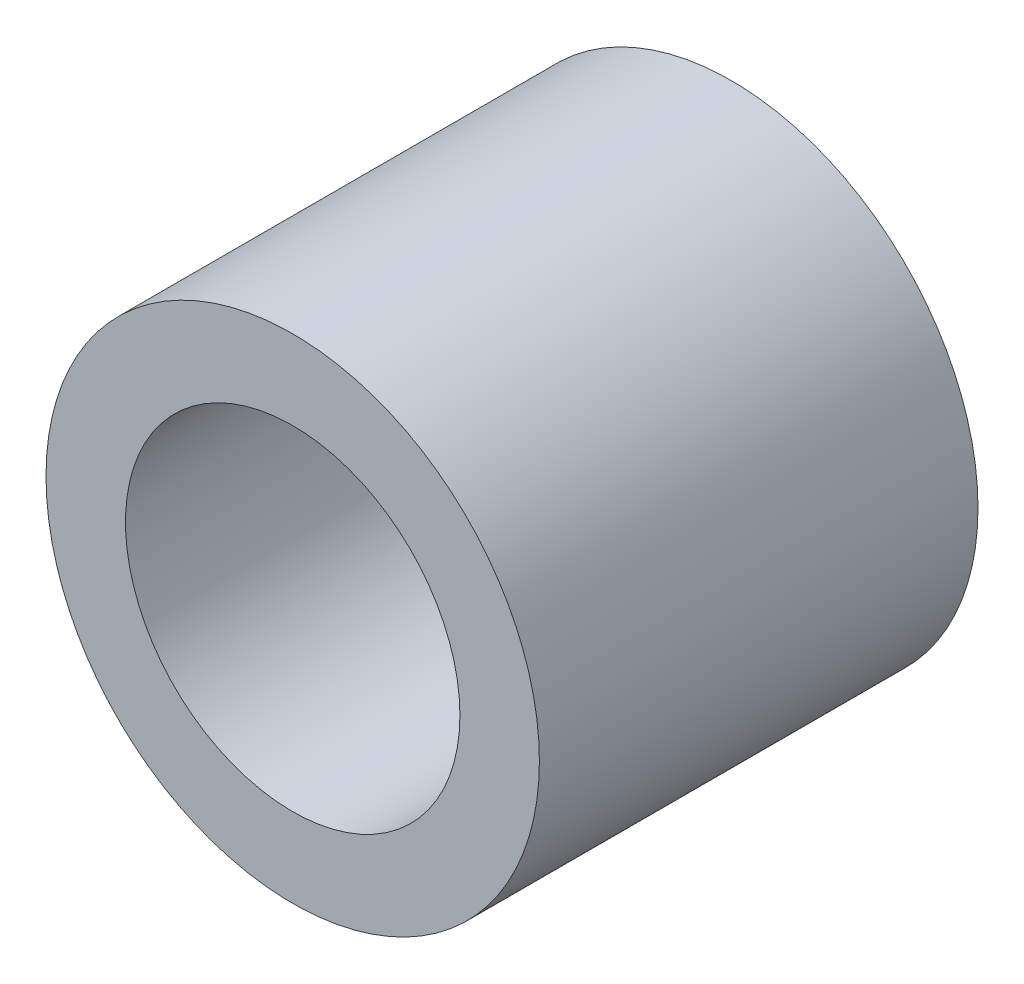
from build123d import *

# Parameters (mm, degrees)
SKETCH_1_R          = 2.25
EXTRUDE_1_DEPTH     = 1.5
SKETCH_3_R          = 2.25
EXTRUDE_2_DEPTH     = 2.5
SKETCH_4_R          = 1.525
CUT_EXTRUDE_1_DEPTH = 3.5


with BuildPart() as part:
    # 草图1 → 凸台-拉伸1 (new body)
    with BuildSketch(Plane.XY):
        Circle(SKETCH_1_R)
    extrude(amount=EXTRUDE_1_DEPTH)

    # 草图3 → 凸台-拉伸2 (add)
    with BuildSketch(Plane.XY.offset(1.5)):
        Circle(SKETCH_3_R)
    extrude(amount=EXTRUDE_2_DEPTH)

    # 草图4 → 切除-拉伸1 (cut, through all)
    with BuildSketch(Plane.XY.offset(1.5)):
        Circle(SKETCH_4_R)
    extrude(amount=CUT_EXTRUDE_1_DEPTH, mode=Mode.SUBTRACT)


solid = part.part
